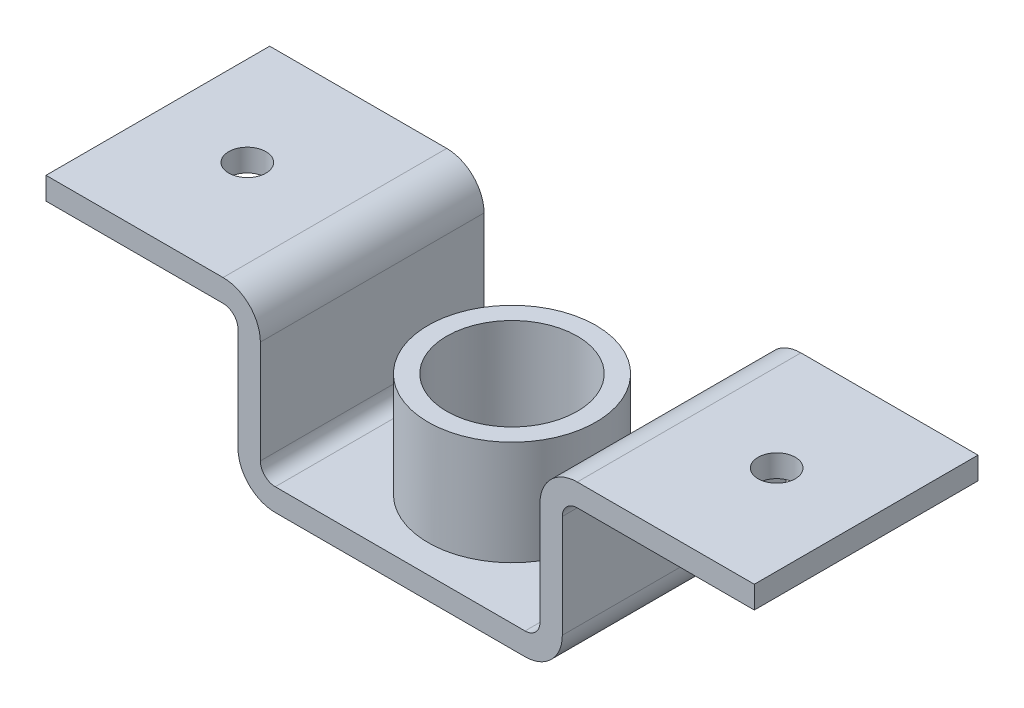
from build123d import *

# Parameters (mm, degrees)
BOSS_EXTRUDE1_DEPTH = 300
SKETCH2_R           = 112.5
SKETCH2_R_2         = 87.5
BOSS_EXTRUDE2_DEPTH = 170
SKETCH3_R           = 37.5
CUT_EXTRUDE3_DEPTH  = 239
CUT_EXTRUDE4_START  = 208
SKETCH5_R           = 25
CUT_EXTRUDE4_DEPTH  = 31


with BuildPart() as part:
    # Sketch1 → Boss-Extrude1 (new body)
    with BuildSketch(Plane.XY):
        with BuildLine():
            Line((-167.5, 0), (167.5, 0))
            ThreePointArc((167.5, 0), (202.855339059, 14.644660941), (217.5, 50))
            Line((217.5, 50), (217.5, 188))
            ThreePointArc((217.5, 188), (223.357864376, 202.142135624), (237.5, 208))
            Line((237.5, 208), (475, 208))
            Line((475, 208), (475, 238))
            Line((475, 238), (237.5, 238))
            ThreePointArc((237.5, 238), (202.144660941, 223.355339059), (187.5, 188))
            Line((187.5, 188), (187.5, 50))
            ThreePointArc((187.5, 50), (181.642135624, 35.857864376), (167.5, 30))
            Line((167.5, 30), (-167.5, 30))
            ThreePointArc((-167.5, 30), (-181.642135624, 35.857864376), (-187.5, 50))
            Line((-187.5, 50), (-187.5, 188))
            ThreePointArc((-187.5, 188), (-202.144660941, 223.355339059), (-237.5, 238))
            Line((-237.5, 238), (-475, 238))
            Line((-475, 238), (-475, 208))
            Line((-475, 208), (-237.5, 208))
            ThreePointArc((-237.5, 208), (-223.357864376, 202.142135624), (-217.5, 188))
            Line((-217.5, 188), (-217.5, 50))
            ThreePointArc((-217.5, 50), (-202.855339059, 14.644660941), (-167.5, 0))
        make_face()
    extrude(amount=BOSS_EXTRUDE1_DEPTH)

    # Sketch2 → Boss-Extrude2 (add)
    with BuildSketch(Plane(origin=(0, 0, 0), x_dir=(1, 0, 0), z_dir=(0, 1, 0))):
        with Locations((0, -150)):
            Circle(SKETCH2_R)
        with Locations((0, -150)):
            Circle(SKETCH2_R_2, mode=Mode.SUBTRACT)
    extrude(amount=BOSS_EXTRUDE2_DEPTH)

    # Sketch3 → Cut-Extrude3 (cut, through all)
    with BuildSketch(Plane(origin=(0, 0, 0), x_dir=(1, 0, 0), z_dir=(0, 1, 0))):
        with Locations((0, -150)):
            Circle(SKETCH3_R)
    extrude(amount=CUT_EXTRUDE3_DEPTH, mode=Mode.SUBTRACT)

    # Sketch5 → Cut-Extrude4 (cut, through all)
    with BuildSketch(Plane(origin=(0, 0, 0), x_dir=(1, 0, 0), z_dir=(0, 1, 0)).offset(CUT_EXTRUDE4_START)):
        with Locations((-355, -150)):
            Circle(SKETCH5_R)
        with Locations((355, -150)):
            Circle(SKETCH5_R)
    extrude(amount=CUT_EXTRUDE4_DEPTH, mode=Mode.SUBTRACT)


solid = part.part
